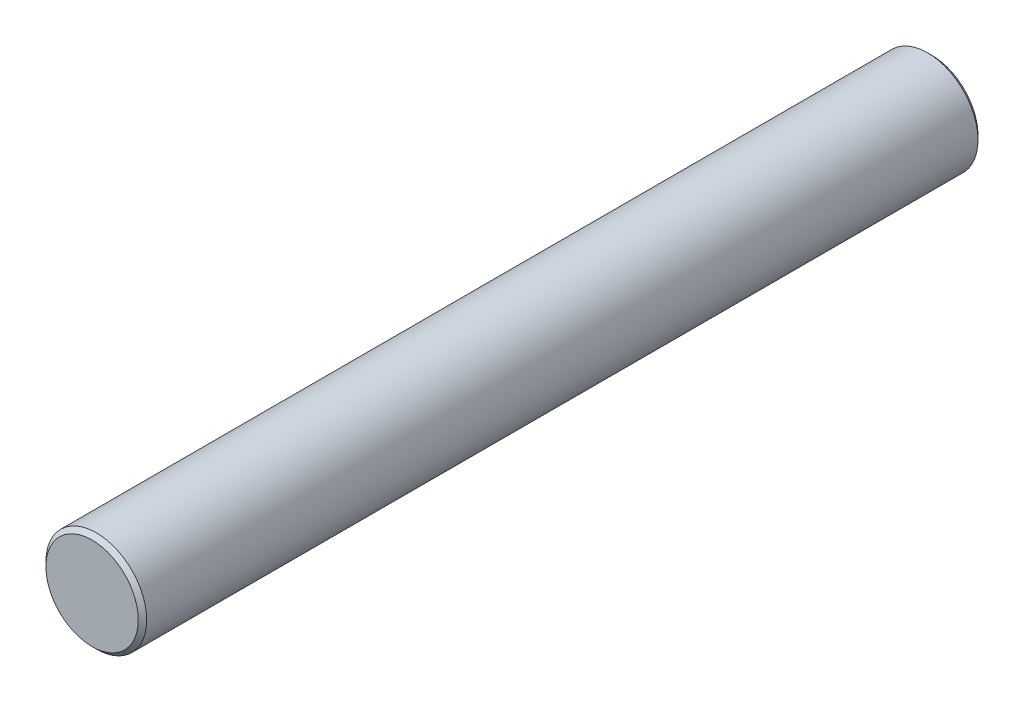
from build123d import *

# Parameters (mm, degrees)
ESQUISSE1_R        = 6
BOSS_EXTRU_1_DEPTH = 100
CHANFREIN1_SIZE    = 0.5


with BuildPart() as part:
    # Esquisse1 → Boss.-Extru.1 (new body)
    with BuildSketch(Plane.XY):
        Circle(ESQUISSE1_R)
    extrude(amount=BOSS_EXTRU_1_DEPTH)

    # Chanfrein1
    chanfrein1_edges = [part.edges().sort_by_distance(p)[0] for p in [
        (-6, 0, 0),
        (-6, 0, 100),
    ]]
    chamfer(chanfrein1_edges, length=CHANFREIN1_SIZE)


solid = part.part
